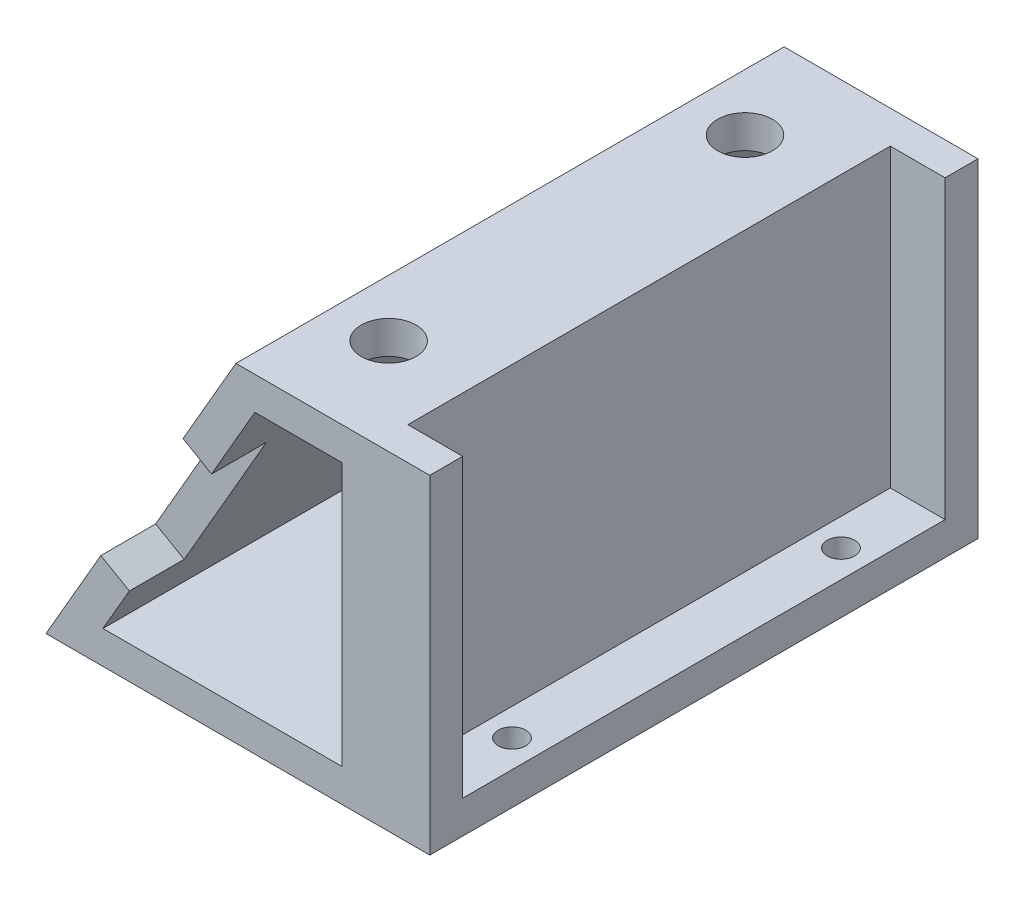
from build123d import *

# Parameters (mm, degrees)
AUFSATZ_LINEAR_AUSTRAGEN1_DEPTH = 50
SKIZZE3_R                       = 1.25
SKIZZE3_R_2                     = 1.5
SCHNITT_LINEAR_AUSTRAGEN1_DEPTH = 3
SKIZZE4_W                       = 5
SKIZZE4_H                       = 44
SCHNITT_LINEAR_AUSTRAGEN2_DEPTH = 27
SKIZZE5_R                       = 2.5
SCHNITT_LINEAR_AUSTRAGEN3_DEPTH = 28
SKIZZE6_R                       = 1.25
SCHNITT_LINEAR_AUSTRAGEN4_DEPTH = 3
SKIZZE7_W                       = 5
SKIZZE7_H                       = 15
SCHNITT_LINEAR_AUSTRAGEN5_DEPTH = 3


with BuildPart() as part:
    # Skizze2 → Aufsatz-Linear austragen1 (new body)
    with BuildSketch(Plane.XY):
        Polygon((-4.170146195, 14.050114253), (-21.49065427, -15.949885747), (13.50934573, -15.949885747), (13.50934573, 14.050114253), align=None)
        Polygon((5.50934573, -12.949885747), (-16.294501848, -12.949885747), (-2.438095387, 11.050114253), (5.50934573, 11.050114253), align=None, mode=Mode.SUBTRACT)
    extrude(amount=AUFSATZ_LINEAR_AUSTRAGEN1_DEPTH)

    # Skizze3 → Schnitt-Linear austragen1 (cut)
    with BuildSketch(Plane.XZ.offset(15.949885747)):
        with Locations((11.00934573, 40)):
            Circle(SKIZZE3_R)
        with Locations((11.00934573, 10)):
            Circle(SKIZZE3_R)
        with Locations((1.00934573, 41.25)):
            Circle(SKIZZE3_R_2)
        with Locations((1.00934573, 8.75)):
            Circle(SKIZZE3_R_2)
    extrude(amount=-SCHNITT_LINEAR_AUSTRAGEN1_DEPTH, mode=Mode.SUBTRACT)

    # Skizze4 → Schnitt-Linear austragen2 (cut)
    with BuildSketch(Plane(origin=(0, 14.050114253, 0), x_dir=(1, 0, 0), z_dir=(0, 1, 0))):
        with Locations((11.00934573, -25)):
            Rectangle(SKIZZE4_W, SKIZZE4_H)
    extrude(amount=-SCHNITT_LINEAR_AUSTRAGEN2_DEPTH, mode=Mode.SUBTRACT)

    # Skizze5 → Schnitt-Linear austragen3 (cut)
    with BuildSketch(Plane(origin=(0, 14.050114253, 0), x_dir=(1, 0, 0), z_dir=(0, 1, 0))):
        with Locations((1.00934573, -41.25)):
            Circle(SKIZZE5_R)
        with Locations((1.00934573, -8.75)):
            Circle(SKIZZE5_R)
    extrude(amount=-SCHNITT_LINEAR_AUSTRAGEN3_DEPTH, mode=Mode.SUBTRACT)

    # Skizze6 → Schnitt-Linear austragen4 (cut)
    with BuildSketch(Plane(origin=(-9.21148758, 5.318254834, 0), x_dir=(0, 0, 1), z_dir=(-0.866025404, 0.5, 0))):
        with Locations((35, -1.917317229)):
            Circle(SKIZZE6_R)
        with Locations((15, -1.917317229)):
            Circle(SKIZZE6_R)
    extrude(amount=-SCHNITT_LINEAR_AUSTRAGEN4_DEPTH, mode=Mode.SUBTRACT)

    # Skizze7 → Schnitt-Linear austragen5 (cut)
    with BuildSketch(Plane(origin=(-9.21148758, 5.318254834, 0), x_dir=(0, 0, 1), z_dir=(-0.866025404, 0.5, 0))):
        with Locations((47.5, -7.05833338)):
            Rectangle(SKIZZE7_W, SKIZZE7_H)
        with Locations((2.5, -7.05833338)):
            Rectangle(SKIZZE7_W, SKIZZE7_H)
    extrude(amount=-SCHNITT_LINEAR_AUSTRAGEN5_DEPTH, mode=Mode.SUBTRACT)


solid = part.part
